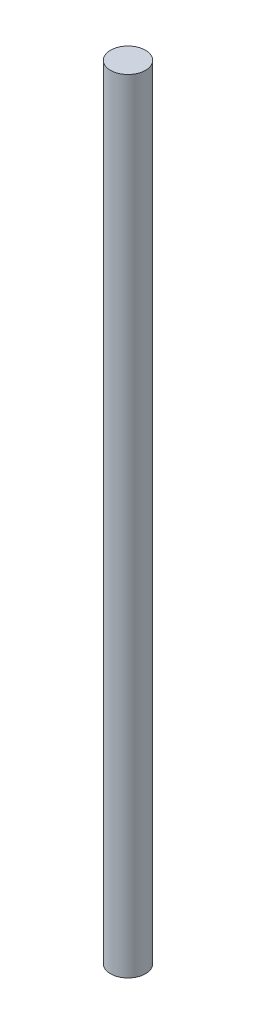
from build123d import *

# Parameters (mm, degrees)
SKETCH1_R           = 3.96875
BOSS_EXTRUDE1_DEPTH = 177.8


with BuildPart() as part:
    # Sketch1 → Boss-Extrude1 (new body)
    with BuildSketch(Plane(origin=(0, 0, 0), x_dir=(1, 0, 0), z_dir=(0, 1, 0))):
        Circle(SKETCH1_R)
    extrude(amount=BOSS_EXTRUDE1_DEPTH)


solid = part.part
